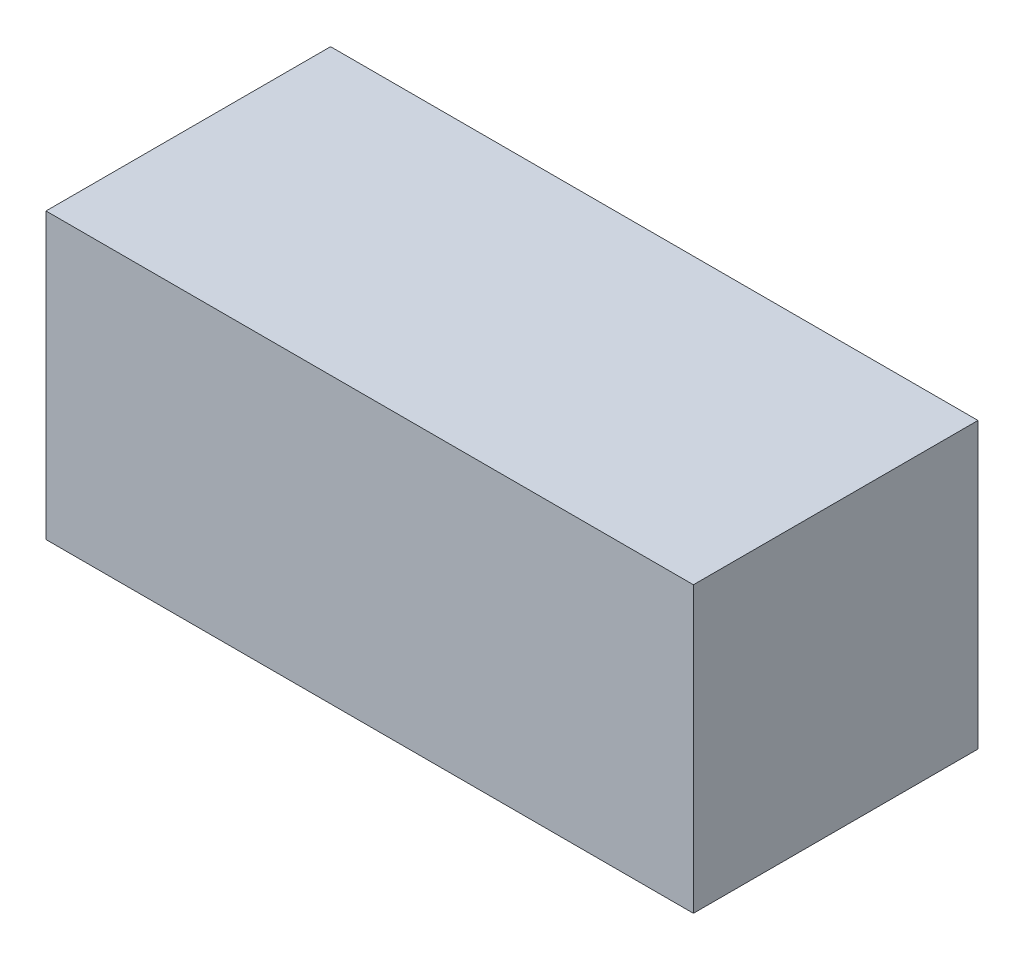
from build123d import *

# Parameters (mm, degrees)
SKETCH1_W           = 1137.5
SKETCH1_H           = 500
BOSS_EXTRUDE1_DEPTH = 500


with BuildPart() as part:
    # Sketch1 → Boss-Extrude1 (new body)
    with BuildSketch(Plane(origin=(0, 0, 0), x_dir=(1, 0, 0), z_dir=(0, 1, 0))):
        Rectangle(SKETCH1_W, SKETCH1_H)
    extrude(amount=BOSS_EXTRUDE1_DEPTH)


solid = part.part
